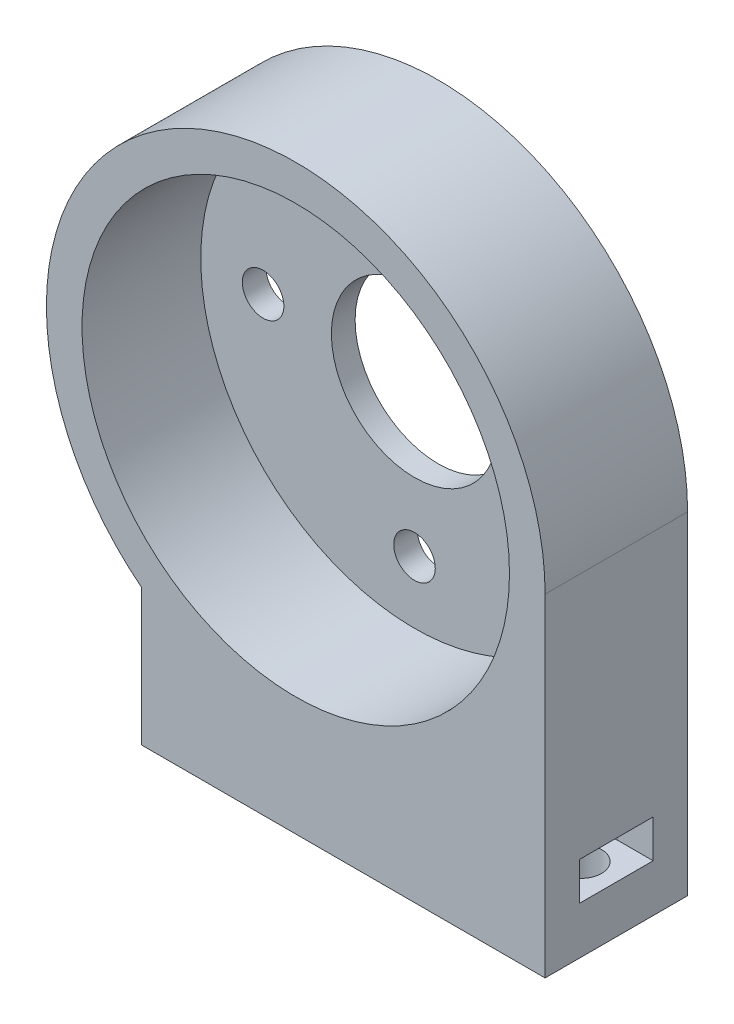
from build123d import *
from build123d.topology import SkipClean

# Parameters (mm, degrees)
CROQUIS1_R              = 18
SALIENTE_EXTRUIR1_DEPTH = 10
SALIENTE_EXTRUIR2_START = -12
CROQUIS2_R              = 7
CROQUIS2_R_2            = 1.75
SALIENTE_EXTRUIR2_DEPTH = 2
CROQUIS7_R              = 1.75
CORTAR_EXTRUIR3_DEPTH   = 8
CORTAR_EXTRUIR4_DEPTH   = 3.2


with BuildPart() as part:
    # Croquis1 → Saliente-Extruir1 (new body)
    with BuildSketch(Plane.XY):
        with BuildLine():
            Line((-13, -28), (21, -28))
            Line((21, -28), (21, 0))
            ThreePointArc((21, 0), (-9.16515139, 18.894443628), (-13, -16.492422502))
            Line((-13, -16.492422502), (-13, -28))
        make_face()
        Circle(CROQUIS1_R, mode=Mode.SUBTRACT)
    extrude(amount=SALIENTE_EXTRUIR1_DEPTH)

    # Croquis2 → Saliente-Extruir2 (add)
    with SkipClean():  # the faces are left unmerged after this step: merging them gives an invalid solid
        with BuildSketch(Plane.XY.offset(10).offset(SALIENTE_EXTRUIR2_START)):
            with BuildLine():
                Line((21, 0), (21, -28))
                Line((21, -28), (-13, -28))
                Line((-13, -28), (-13, -16.492422502))
                ThreePointArc((-13, -16.492422502), (-9.16515139, 18.894443628), (21, 0))
            make_face()
            Circle(CROQUIS2_R, mode=Mode.SUBTRACT)
            with Locations((0, -12.75)):
                Circle(CROQUIS2_R_2, mode=Mode.SUBTRACT)
            with Locations((0, 12.75)):
                Circle(CROQUIS2_R_2, mode=Mode.SUBTRACT)
            with Locations((-12.75, 0)):
                Circle(CROQUIS2_R_2, mode=Mode.SUBTRACT)
        extrude(amount=SALIENTE_EXTRUIR2_DEPTH)

    # Croquis7 → Cortar-Extruir3 (cut)
    with SkipClean():  # the faces are left unmerged after this step: merging them gives an invalid solid
        with BuildSketch(Plane.XZ.offset(28)):
            with Locations((-10, 4)):
                Circle(CROQUIS7_R)
            with Locations((18, 4)):
                Circle(CROQUIS7_R)
        extrude(amount=-CORTAR_EXTRUIR3_DEPTH, mode=Mode.SUBTRACT)

    # Croquis8 → Cortar-Extruir4 (cut)
    with SkipClean():  # the faces are left unmerged after this step: merging them gives an invalid solid
        with BuildSketch(Plane(origin=(0, -24, 0), x_dir=(-1, 0, 0), z_dir=(0, -1, 0))):
            with BuildLine():
                Line((-18, -0.9), (-21, -0.9))
                Line((-21, -0.9), (-21, -7.1))
                Line((-21, -7.1), (-18, -7.1))
                ThreePointArc((-18, -7.1), (-14.9, -4), (-18, -0.9))
            make_face()
            with BuildLine():
                Line((10, -0.9), (13, -0.9))
                Line((13, -0.9), (13, -7.1))
                Line((13, -7.1), (10, -7.1))
                ThreePointArc((10, -7.1), (6.9, -4), (10, -0.9))
            make_face()
        extrude(amount=-CORTAR_EXTRUIR4_DEPTH, mode=Mode.SUBTRACT)


solid = part.part
